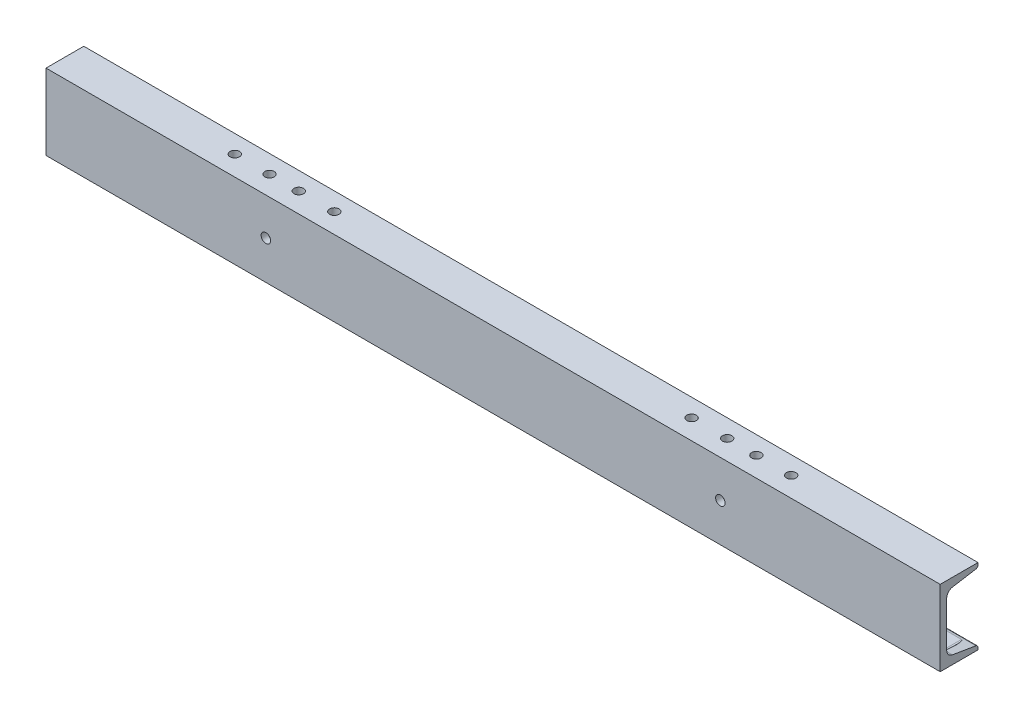
from build123d import *

# Parameters (mm, degrees)
STRUCTURAL_MEMBER1_DEPTH = 900
SKETCH12_R               = 4.7625
CUT_EXTRUDE1_DEPTH       = 454.210052427
CUT_EXTRUDE2_DEPTH       = 40
SKETCH16_R               = 4.7625
CUT_EXTRUDE3_DEPTH       = 454.210052526
SKETCH17_R               = 4.7625
CUT_EXTRUDE4_DEPTH       = 454.210052526


with BuildPart() as part:
    # Sketch11 → Structural Member1 (new body)
    with BuildSketch(Plane(origin=(-450, 0, 0), x_dir=(0, 0, -1), z_dir=(1, 0, 0))):
        with BuildLine():
            Line((0, -38.1), (0, 38.1))
            Line((0, 38.1), (38.0492, 38.1))
            Line((38.0492, 38.1), (38.0492, 35.942335136))
            ThreePointArc((38.0492, 35.942335136), (37.447280466, 34.300554363), (35.926803066, 33.436899509))
            Line((35.926803066, 33.436899509), (12.283671721, 29.496090157))
            ThreePointArc((12.283671721, 29.496090157), (8.178382741, 27.164222052), (6.5532, 22.731413966))
            Line((6.5532, 22.731413966), (6.5532, -22.731413966))
            ThreePointArc((6.5532, -22.731413966), (8.178382741, -27.164222052), (12.283671721, -29.496090157))
            Line((12.283671721, -29.496090157), (35.926803066, -33.436899509))
            ThreePointArc((35.926803066, -33.436899509), (37.447280466, -34.300554363), (38.0492, -35.942335136))
            Line((38.0492, -35.942335136), (38.0492, -38.1))
            Line((38.0492, -38.1), (0, -38.1))
        make_face()
    extrude(amount=STRUCTURAL_MEMBER1_DEPTH)

    # Sketch12 → Cut-Extrude1 (cut, through all)
    with BuildSketch(Plane(origin=(0, 0, 0), x_dir=(1, 0, 0), z_dir=(0, 1, 0))):
        with Locations(Location((-425, 20, 0), (0, 0, 270))):
            Circle(SKETCH12_R)
        with Locations(Location((425, 20, 0), (0, 0, 270))):
            Circle(SKETCH12_R)
    extrude(amount=-CUT_EXTRUDE1_DEPTH, mode=Mode.SUBTRACT)

    # Sketch15 → Cut-Extrude2 (cut)
    with BuildSketch(Plane(origin=(0, 0, -6.5532), x_dir=(-1, 0, 0), z_dir=(0, 0, -1))):
        with BuildLine():
            Line((-412.5, -33.1), (-437.5, -33.1))
            ThreePointArc((-437.5, -33.1), (-442.5, -28.1), (-437.5, -23.1))
            Line((-437.5, -23.1), (-412.5, -23.1))
            ThreePointArc((-412.5, -23.1), (-407.5, -28.1), (-412.5, -33.1))
        make_face()
        with BuildLine():
            Line((412.5, -33.1), (437.5, -33.1))
            ThreePointArc((437.5, -33.1), (442.5, -28.1), (437.5, -23.1))
            Line((437.5, -23.1), (412.5, -23.1))
            ThreePointArc((412.5, -23.1), (407.5, -28.1), (412.5, -33.1))
        make_face()
    extrude(amount=CUT_EXTRUDE2_DEPTH, mode=Mode.SUBTRACT)

    # Sketch16 → Cut-Extrude3 (cut, through all)
    with BuildSketch(Plane(origin=(0, 0, 0), x_dir=(1, 0, 0), z_dir=(0, 1, 0))):
        with Locations(Location((-215.6, 20, 0), (0, 0, 270))):
            Circle(SKETCH16_R)
        with Locations(Location((-179.8, 20, 0), (0, 0, 270))):
            Circle(SKETCH16_R)
        with Locations(Location((179.8, 20, 0), (0, 0, 90))):
            Circle(SKETCH16_R)
        with Locations(Location((215.6, 20, 0), (0, 0, 90))):
            Circle(SKETCH16_R)
        with Locations(Location((-245, 20, 0), (0, 0, 270))):
            Circle(SKETCH16_R)
        with Locations(Location((-280, 20, 0), (0, 0, 270))):
            Circle(SKETCH16_R)
        with Locations(Location((245, 20, 0), (0, 0, 90))):
            Circle(SKETCH16_R)
        with Locations(Location((280, 20, 0), (0, 0, 90))):
            Circle(SKETCH16_R)
    extrude(amount=CUT_EXTRUDE3_DEPTH, mode=Mode.SUBTRACT)

    # Sketch17 → Cut-Extrude4 (cut, through all)
    with BuildSketch(Plane.XY):
        with Locations((228.7, 0.6)):
            Circle(SKETCH17_R)
        with Locations((-228.7, 0.6)):
            Circle(SKETCH17_R)
    extrude(amount=-CUT_EXTRUDE4_DEPTH, mode=Mode.SUBTRACT)


solid = part.part
